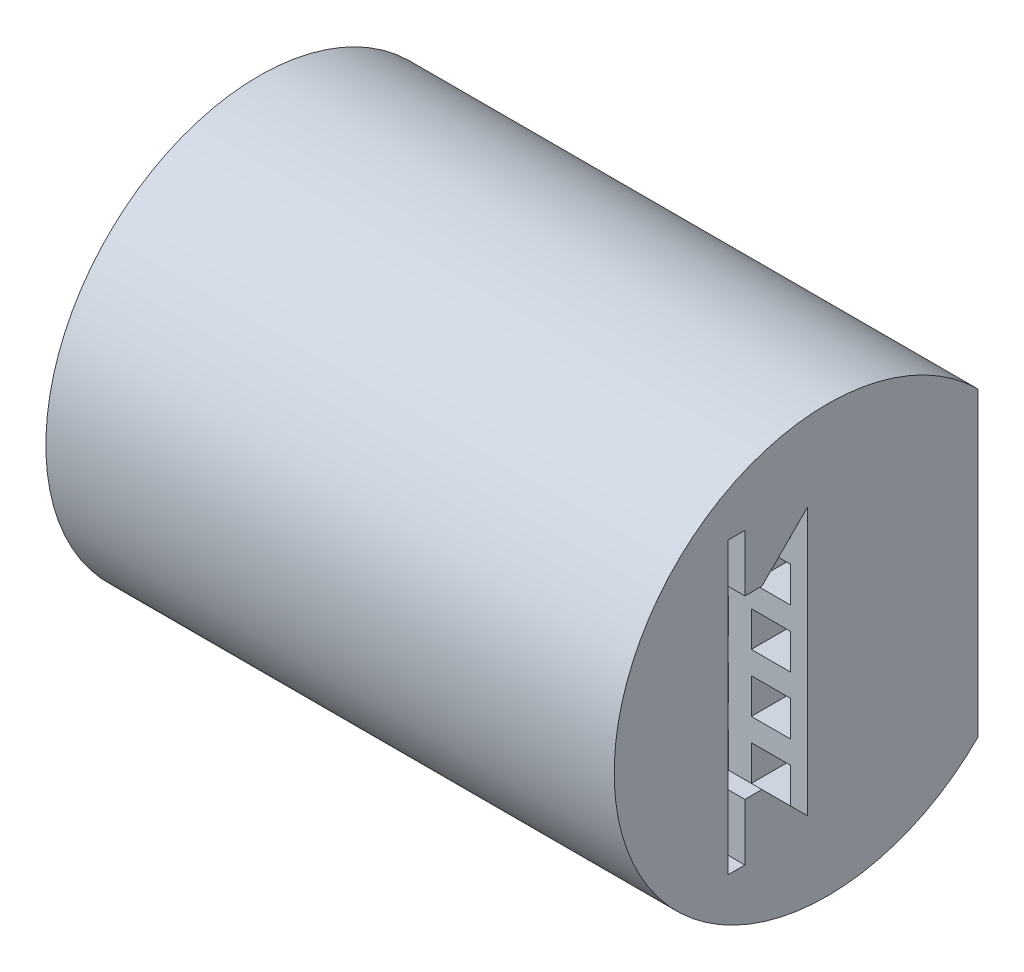
from build123d import *

# Parameters (mm, degrees)
BOSS_EXTRUDE1_DEPTH = 10
SKETCH2_W           = 1.377777778
SKETCH2_H           = 1.241320344
SKETCH2_H_2         = 1.241320343
SKETCH2_W_2         = 1.377777777
CUT_EXTRUDE1_DEPTH  = 6


with BuildPart() as part:
    # Sketch1 → Boss-Extrude1 (new body, symmetric)
    with BuildSketch(Plane(origin=(0, 0, 0), x_dir=(0, 0, -1), z_dir=(1, 0, 0))):
        with BuildLine():
            Line((5.303300859, 5.303300859), (5.303300859, -5.303300859))
            ThreePointArc((5.303300859, -5.303300859), (-7.5, 0), (5.303300859, 5.303300859))
        make_face()
        Polygon((-3.5, -5.1), (-3.5, 5.1), (-2.9, 5.1), (-2.9, 3.1), (-2.3, 3.1), (-0.696699141, 4.703300859), (-0.696699141, -4.703300859), (-2.3, -3.1), (-2.9, -3.1), (-2.9, -5.1), align=None, mode=Mode.SUBTRACT)
    extrude(amount=BOSS_EXTRUDE1_DEPTH, both=True)

    # Sketch2 → Cut-Extrude1 (cut)
    with BuildSketch(Plane(origin=(0, 0, -5.303300859), x_dir=(-1, 0, 0), z_dir=(0, 0, -1))):
        with Locations((-6.533333333, -4.082640687)):
            Rectangle(SKETCH2_W, SKETCH2_H)
        with Locations((-8.711111111, -4.082640687)):
            Rectangle(SKETCH2_W, SKETCH2_H)
        with Locations((-6.533333333, -2.041320344)):
            Rectangle(SKETCH2_W, SKETCH2_H_2)
        with Locations((-6.533333333, 0)):
            Rectangle(SKETCH2_W, SKETCH2_H)
        with Locations((-8.711111111, -2.041320344)):
            Rectangle(SKETCH2_W, SKETCH2_H_2)
        with Locations((-8.711111111, 0)):
            Rectangle(SKETCH2_W, SKETCH2_H)
        with Locations((-4.355555556, -4.082640687)):
            Rectangle(SKETCH2_W_2, SKETCH2_H)
        with Locations((-2.177777778, -4.082640687)):
            Rectangle(SKETCH2_W, SKETCH2_H)
        with Locations((0, -4.082640687)):
            Rectangle(SKETCH2_W, SKETCH2_H)
        with Locations((2.177777778, -4.082640687)):
            Rectangle(SKETCH2_W, SKETCH2_H)
        with Locations((4.355555556, -4.082640687)):
            Rectangle(SKETCH2_W_2, SKETCH2_H)
        with Locations((6.533333333, -4.082640687)):
            Rectangle(SKETCH2_W, SKETCH2_H)
        with Locations((8.711111111, -4.082640687)):
            Rectangle(SKETCH2_W, SKETCH2_H)
        with Locations((-4.355555556, -2.041320344)):
            Rectangle(SKETCH2_W_2, SKETCH2_H_2)
        with Locations((-2.177777778, -2.041320344)):
            Rectangle(SKETCH2_W, SKETCH2_H_2)
        with Locations((0, -2.041320344)):
            Rectangle(SKETCH2_W, SKETCH2_H_2)
        with Locations((2.177777778, -2.041320344)):
            Rectangle(SKETCH2_W, SKETCH2_H_2)
        with Locations((4.355555556, -2.041320344)):
            Rectangle(SKETCH2_W_2, SKETCH2_H_2)
        with Locations((6.533333333, -2.041320344)):
            Rectangle(SKETCH2_W, SKETCH2_H_2)
        with Locations((8.711111111, -2.041320344)):
            Rectangle(SKETCH2_W, SKETCH2_H_2)
        with Locations((-4.355555556, 0)):
            Rectangle(SKETCH2_W_2, SKETCH2_H)
        with Locations((-2.177777778, 0)):
            Rectangle(SKETCH2_W, SKETCH2_H)
        Rectangle(SKETCH2_W, SKETCH2_H)
        with Locations((2.177777778, 0)):
            Rectangle(SKETCH2_W, SKETCH2_H)
        with Locations((4.355555556, 0)):
            Rectangle(SKETCH2_W_2, SKETCH2_H)
        with Locations((6.533333333, 0)):
            Rectangle(SKETCH2_W, SKETCH2_H)
        with Locations((8.711111111, 0)):
            Rectangle(SKETCH2_W, SKETCH2_H)
        with Locations((-8.711111111, 2.041320344)):
            Rectangle(SKETCH2_W, SKETCH2_H_2)
        with Locations((-6.533333333, 2.041320344)):
            Rectangle(SKETCH2_W, SKETCH2_H_2)
        with Locations((-4.355555556, 2.041320344)):
            Rectangle(SKETCH2_W_2, SKETCH2_H_2)
        with Locations((-2.177777778, 2.041320344)):
            Rectangle(SKETCH2_W, SKETCH2_H_2)
        with Locations((0, 2.041320344)):
            Rectangle(SKETCH2_W, SKETCH2_H_2)
        with Locations((2.177777778, 2.041320344)):
            Rectangle(SKETCH2_W, SKETCH2_H_2)
        with Locations((4.355555556, 2.041320344)):
            Rectangle(SKETCH2_W_2, SKETCH2_H_2)
        with Locations((6.533333333, 2.041320344)):
            Rectangle(SKETCH2_W, SKETCH2_H_2)
        with Locations((8.711111111, 2.041320344)):
            Rectangle(SKETCH2_W, SKETCH2_H_2)
        with Locations((-8.711111111, 4.082640687)):
            Rectangle(SKETCH2_W, SKETCH2_H)
        with Locations((-6.533333333, 4.082640687)):
            Rectangle(SKETCH2_W, SKETCH2_H)
        with Locations((-4.355555556, 4.082640687)):
            Rectangle(SKETCH2_W_2, SKETCH2_H)
        with Locations((-2.177777778, 4.082640687)):
            Rectangle(SKETCH2_W, SKETCH2_H)
        with Locations((0, 4.082640687)):
            Rectangle(SKETCH2_W, SKETCH2_H)
        with Locations((2.177777778, 4.082640687)):
            Rectangle(SKETCH2_W, SKETCH2_H)
        with Locations((4.355555556, 4.082640687)):
            Rectangle(SKETCH2_W_2, SKETCH2_H)
        with Locations((6.533333333, 4.082640687)):
            Rectangle(SKETCH2_W, SKETCH2_H)
        with Locations((8.711111111, 4.082640687)):
            Rectangle(SKETCH2_W, SKETCH2_H)
    extrude(amount=-CUT_EXTRUDE1_DEPTH, mode=Mode.SUBTRACT)


solid = part.part
